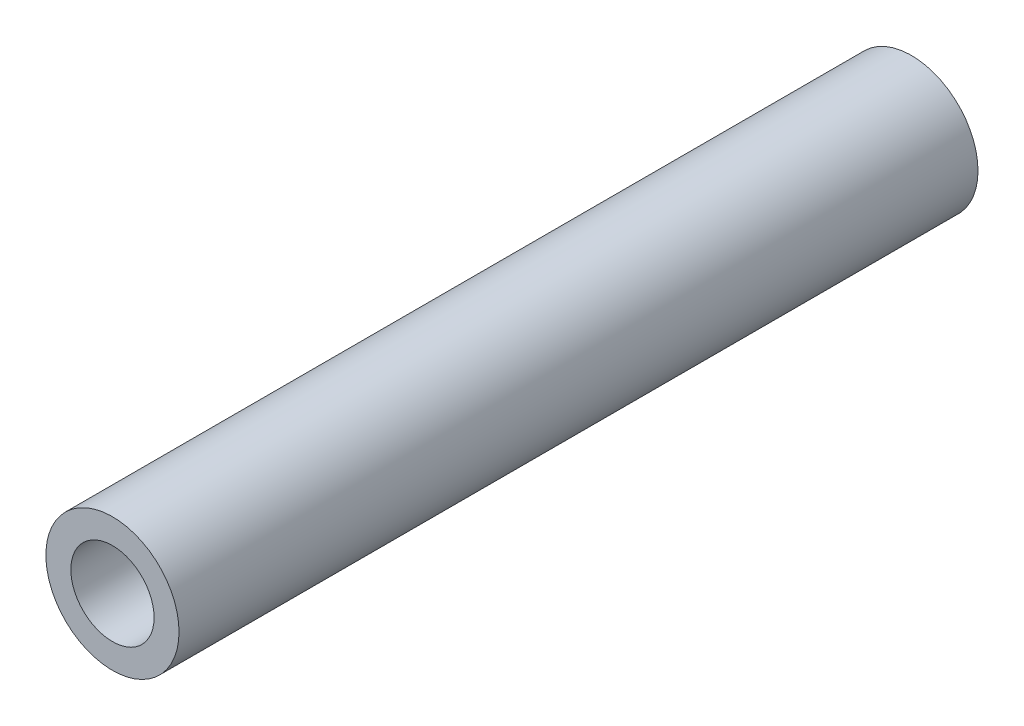
from build123d import *

# Parameters (mm, degrees)
SKETCH_1_R      = 4
SKETCH_1_R_2    = 2.5
EXTRUDE_1_DEPTH = 48


with BuildPart() as part:
    # 草图1 → 凸台-拉伸1 (new body)
    with BuildSketch(Plane.XY):
        Circle(SKETCH_1_R)
        Circle(SKETCH_1_R_2, mode=Mode.SUBTRACT)
    extrude(amount=EXTRUDE_1_DEPTH)


solid = part.part
